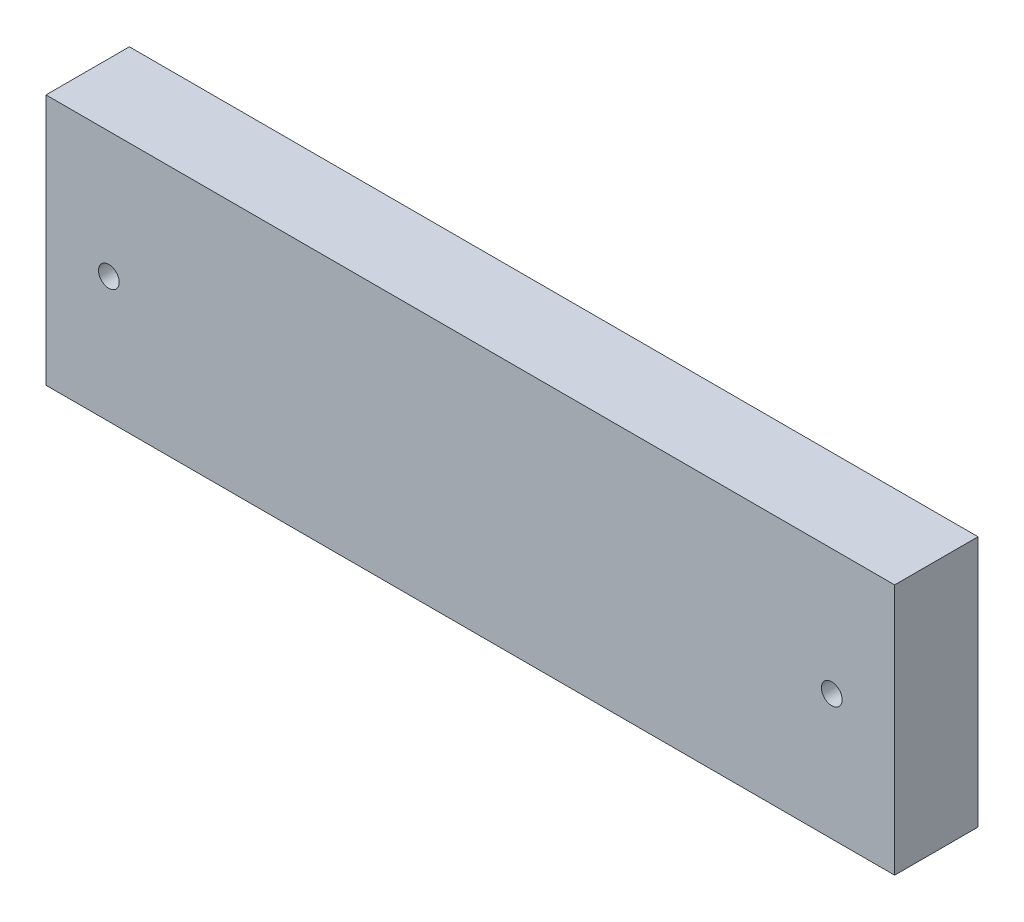
from build123d import *

# Parameters (mm, degrees)
SKETCH1_W             = 135
SKETCH1_H             = 40
BOSS_EXTRUDE1_DEPTH   = 6.63
M4X0_7_TAPPED_HOLE1_D = 3.3


with BuildPart() as part:
    # Sketch1 → Boss-Extrude1 (new, symmetric)
    with BuildSketch(Plane.XY):
        Rectangle(SKETCH1_W, SKETCH1_H)
    extrude(amount=BOSS_EXTRUDE1_DEPTH, both=True)

    # M4x0.7 Tapped Hole1 (through all)
    with Locations(Plane.XY.offset(6.63)):
        with Locations((57.5, 0), (-57.5, 0)):
            Hole(M4X0_7_TAPPED_HOLE1_D / 2)


solid = part.part
